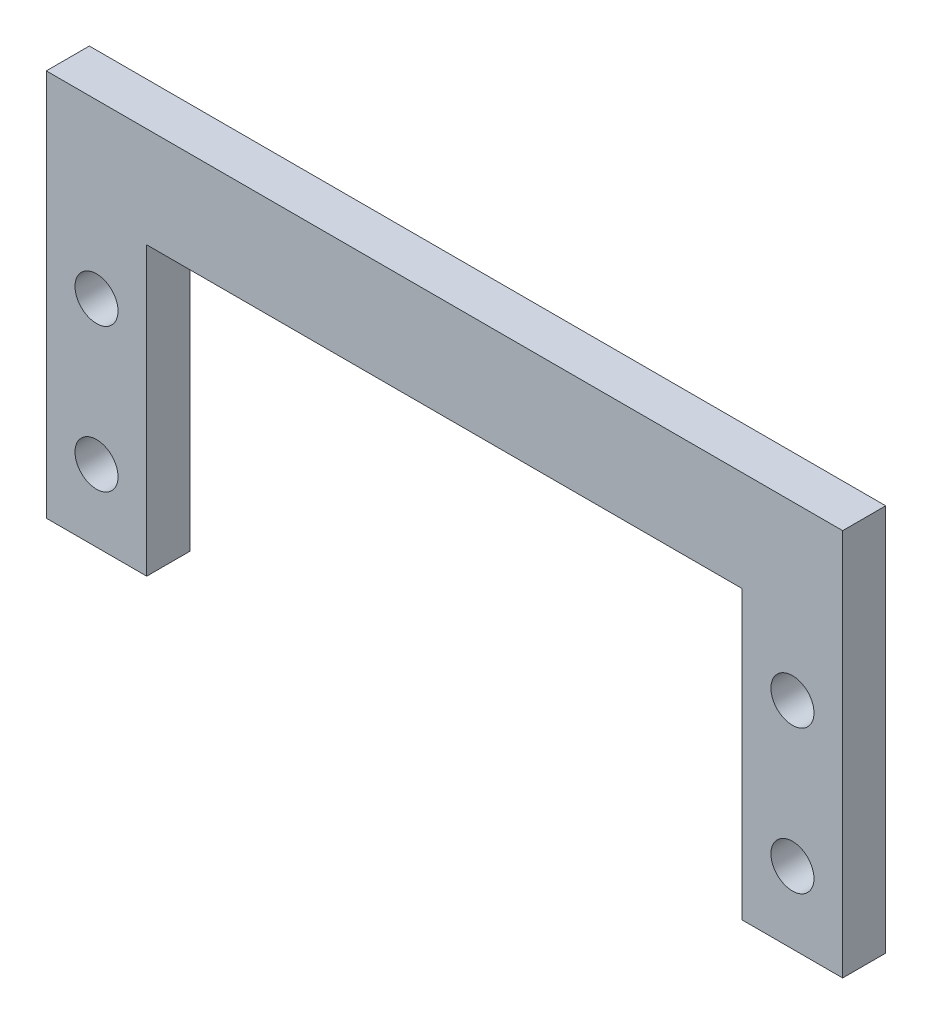
from build123d import *

# Parameters (mm, degrees)
SKIZZE3_R                       = 1.5
AUFSATZ_LINEAR_AUSTRAGEN1_DEPTH = 1.5


with BuildPart() as part:
    # Skizze3 → Aufsatz-Linear austragen1 (new body, symmetric)
    with BuildSketch(Plane.XY):
        Polygon((-30.75, 10), (10.75, 10), (10.75, -10), (17.75, -10), (17.75, 17), (-37.75, 17), (-37.75, -10), (-30.75, -10), align=None)
        with Locations((-34.25, 5)):
            Circle(SKIZZE3_R, mode=Mode.SUBTRACT)
        with Locations((-34.25, -5)):
            Circle(SKIZZE3_R, mode=Mode.SUBTRACT)
        with Locations((14.25, 5)):
            Circle(SKIZZE3_R, mode=Mode.SUBTRACT)
        with Locations((14.25, -5)):
            Circle(SKIZZE3_R, mode=Mode.SUBTRACT)
    extrude(amount=AUFSATZ_LINEAR_AUSTRAGEN1_DEPTH, both=True)


solid = part.part
